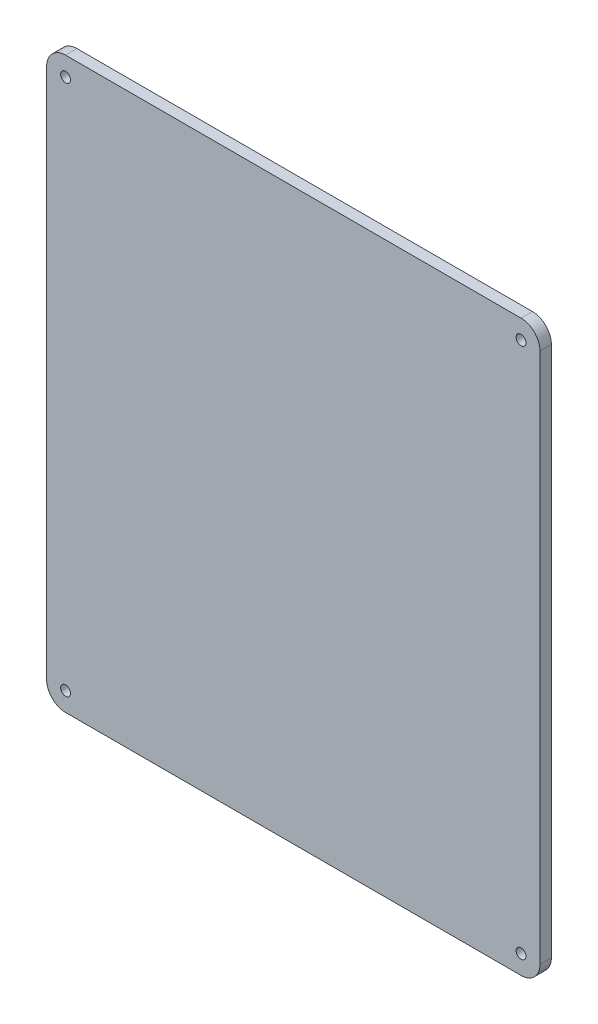
from build123d import *

# Parameters (mm, degrees)
EXTRUDE_3_DEPTH     = 3
SKETCH_2_R          = 1.3
CUT_EXTRUDE_1_DEPTH = 3


with BuildPart() as part:
    # ｽｹｯﾁ1 → ﾎﾞｽ - 押し出し3 (new body)
    with BuildSketch(Plane.XY):
        with BuildLine():
            Line((-60, 75), (60, 75))
            ThreePointArc((60, 75), (63.535533906, 73.535533906), (65, 70))
            Line((65, 70), (65, -70))
            ThreePointArc((65, -70), (63.535533906, -73.535533906), (60, -75))
            Line((60, -75), (-60, -75))
            ThreePointArc((-60, -75), (-63.535533906, -73.535533906), (-65, -70))
            Line((-65, -70), (-65, 70))
            ThreePointArc((-65, 70), (-63.535533906, 73.535533906), (-60, 75))
        make_face()
    extrude(amount=EXTRUDE_3_DEPTH)

    # ｽｹｯﾁ2 → ｶｯﾄ - 押し出し1 (cut)
    with BuildSketch(Plane.XY.offset(3)):
        with Locations((-60, 70)):
            Circle(SKETCH_2_R)
        with Locations((60, 70)):
            Circle(SKETCH_2_R)
        with Locations((60, -70)):
            Circle(SKETCH_2_R)
        with Locations((-60, -70)):
            Circle(SKETCH_2_R)
    extrude(amount=-CUT_EXTRUDE_1_DEPTH, mode=Mode.SUBTRACT)


solid = part.part
